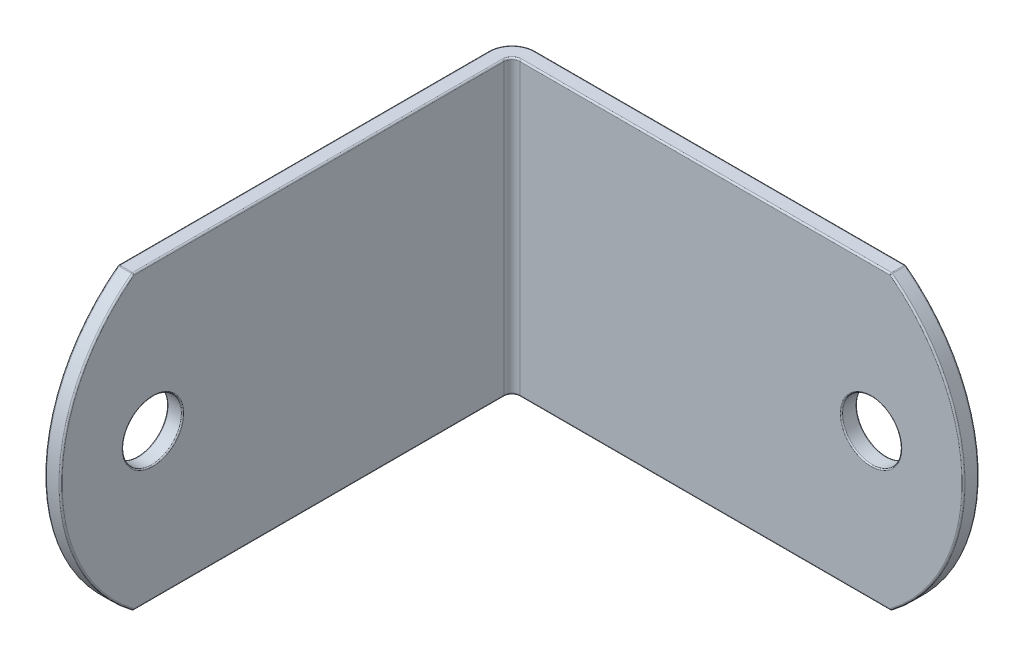
from build123d import *

# Parameters (mm, degrees)
BOSS_EXTRUDE1_START = 11.90625
BOSS_EXTRUDE1_DEPTH = 23.8125
SKETCH5_W           = 1.27
SKETCH5_H           = 2.413
SKETCH6_W           = 2.413
SKETCH6_H           = 1.27
CUT_EXTRUDE1_DEPTH  = 2.27
CUT_EXTRUDE2_DEPTH  = 2.27
FILLET1_R           = 0.127
FILLET2_R           = 0.09652


with BuildPart() as part:
    # Sketch4 → Boss-Extrude1 (new body)
    with BuildSketch(Plane(origin=(0, 0, 0), x_dir=(1, 0, 0), z_dir=(0, 1, 0)).offset(BOSS_EXTRUDE1_START)):
        with BuildLine():
            Line((-19.05, -19.05), (-17.78, -19.05))
            Line((-17.78, -19.05), (-17.78, 17.145))
            ThreePointArc((-17.78, 17.145), (-17.594012806, 17.594012806), (-17.145, 17.78))
            Line((-17.145, 17.78), (19.05, 17.78))
            Line((19.05, 17.78), (19.05, 19.05))
            Line((19.05, 19.05), (-17.145, 19.05))
            ThreePointArc((-17.145, 19.05), (-18.492038418, 18.492038418), (-19.05, 17.145))
            Line((-19.05, 17.145), (-19.05, -19.05))
        make_face()
    extrude(amount=-BOSS_EXTRUDE1_DEPTH)

    # Sketch5 → Cut-Revolve1 (revolve, cut)
    with BuildSketch(Plane(origin=(0, 0, 0), x_dir=(1, 0, 0), z_dir=(0, 1, 0))):
        with Locations((-18.415, -10.302875)):
            Rectangle(SKETCH5_W, SKETCH5_H)
    revolve(axis=Axis((-19.05, 0, 11.509375), (1, 0, 0)), mode=Mode.SUBTRACT)

    # Sketch6 → Cut-Revolve2 (revolve, cut)
    with BuildSketch(Plane(origin=(0, 0, 0), x_dir=(1, 0, 0), z_dir=(0, 1, 0))):
        with Locations((12.715875, 18.415)):
            Rectangle(SKETCH6_W, SKETCH6_H)
    revolve(axis=Axis((11.509375, 0, -19.05), (0, 0, 1)), mode=Mode.SUBTRACT)

    # Sketch7 → Cut-Extrude1 (cut, through all)
    with BuildSketch(Plane(origin=(-17.78, 0, 0), x_dir=(0, 0, -1), z_dir=(1, 0, 0))):
        with BuildLine():
            ThreePointArc((-19.05, 0), (-17.478779679, 6.655796089), (-13.096875, 11.90625))
            Line((-13.096875, 11.90625), (-19.05, 11.90625))
            Line((-19.05, 11.90625), (-19.05, 0))
        make_face()
        with BuildLine():
            ThreePointArc((-13.096875, -11.90625), (-17.478779679, -6.655796089), (-19.05, 0))
            Line((-19.05, 0), (-19.05, -11.90625))
            Line((-19.05, -11.90625), (-13.096875, -11.90625))
        make_face()
    extrude(amount=-CUT_EXTRUDE1_DEPTH, mode=Mode.SUBTRACT)

    # Sketch8 → Cut-Extrude2 (cut, through all)
    with BuildSketch(Plane.XY.offset(-17.78)):
        with BuildLine():
            Line((19.05, 11.90625), (13.096875, 11.90625))
            ThreePointArc((13.096875, 11.90625), (17.478779679, 6.655796089), (19.05, 0))
            Line((19.05, 0), (19.05, 11.90625))
        make_face()
        with BuildLine():
            Line((19.05, -11.90625), (19.05, 0))
            ThreePointArc((19.05, 0), (17.478779679, -6.655796089), (13.096875, -11.90625))
            Line((13.096875, -11.90625), (19.05, -11.90625))
        make_face()
    extrude(amount=-CUT_EXTRUDE2_DEPTH, mode=Mode.SUBTRACT)

    # Fillet1
    fillet1_edges = [part.edges().sort_by_distance(p)[0] for p in [
        (-19.05, 11.90625, -2.0240625),
        (-17.594012806, -11.90625, -17.594012806),
        (-2.0240625, -11.90625, -17.78),
        (-18.492038418, -11.90625, -18.492038418),
        (-17.78, 11.90625, -2.0240625),
        (-17.78, 0, 19.05),
        (-18.415, 11.90625, 13.096875),
        (-19.05, 0, 19.05),
        (-19.05, -11.90625, -2.0240625),
        (-17.78, -11.90625, -2.0240625),
        (-18.415, -11.90625, 13.096875),
        (-2.0240625, 11.90625, -19.05),
        (13.096875, 11.90625, -18.415),
        (19.05, 0, -19.05),
        (19.05, 0, -17.78),
        (-2.0240625, -11.90625, -19.05),
        (13.096875, -11.90625, -18.415),
        (-18.492038418, 11.90625, -18.492038418),
        (-2.0240625, 11.90625, -17.78),
        (-17.594012806, 11.90625, -17.594012806),
    ]]
    fillet(fillet1_edges, radius=FILLET1_R)

    # Fillet2
    fillet2_edges = [part.edges().sort_by_distance(p)[0] for p in [
        (-19.05, 0, 13.922375),
        (-17.78, 0, 13.922375),
        (9.096375, 0, -17.78),
        (9.096375, 0, -19.05),
    ]]
    fillet(fillet2_edges, radius=FILLET2_R)


solid = part.part
